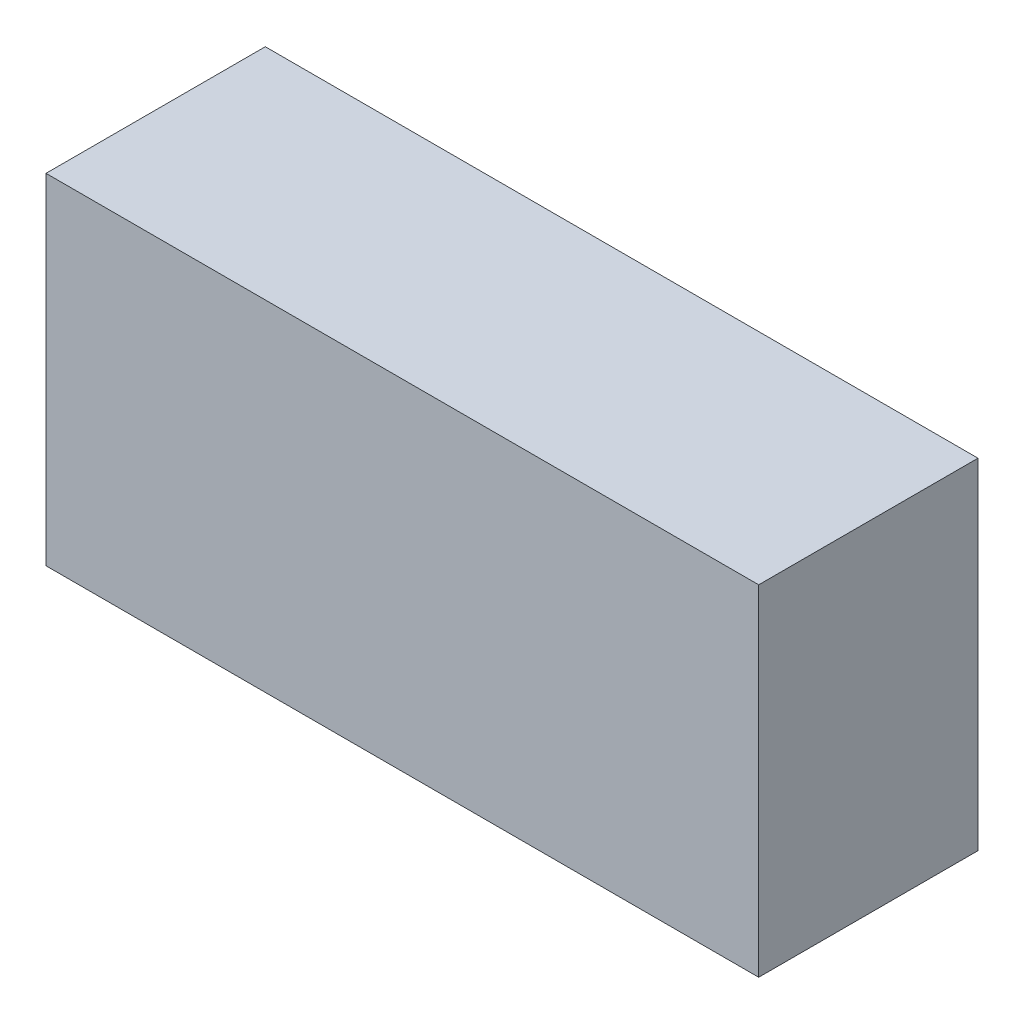
from build123d import *

# Parameters (mm, degrees)
SKETCH_1_W      = 19.5
SKETCH_1_H      = 6
EXTRUDE_1_DEPTH = 9.3
SKETCH_2_W      = 0.6
SKETCH_2_H      = 0.3
EXTRUDE_2_DEPTH = 3
EXTRUDE_3_DEPTH = 0.2


with BuildPart() as part:
    # Эскиз1 → Бобышка-Вытянуть1 (new body)
    with BuildSketch(Plane(origin=(0, 0, 0), x_dir=(1, 0, 0), z_dir=(0, 1, 0))):
        Rectangle(SKETCH_1_W, SKETCH_1_H)
    extrude(amount=EXTRUDE_1_DEPTH)

    # Эскиз2 → Бобышка-Вытянуть2 (add)
    with BuildSketch(Plane.XZ):
        with Locations((-7.62, -1.35)):
            Rectangle(SKETCH_2_W, SKETCH_2_H)
        with Locations((-5.08, -1.35)):
            Rectangle(SKETCH_2_W, SKETCH_2_H)
        with Locations((0, -1.35)):
            Rectangle(SKETCH_2_W, SKETCH_2_H)
        with Locations((5.08, -1.35)):
            Rectangle(SKETCH_2_W, SKETCH_2_H)
    extrude(amount=EXTRUDE_2_DEPTH)

    # Эскиз3 → Бобышка-Вытянуть3 (add)
    with BuildSketch(Plane(origin=(0, 9.3, 0), x_dir=(1, 0, 0), z_dir=(0, 1, 0))):
        with BuildLine():
            Line((-5.993653669, -1.1506083), (-5.993653669, 1.495225034))
            Line((-5.993653669, 1.495225034), (-5.726526265, 1.495225034))
            add(Edge.make_bspline(
                [(-5.726526265, 1.495225034), (-5.703199399, 1.494894605), (-5.65827213, 1.494258204), (-5.593328368, 1.490121291), (-5.533294043, 1.482863062), (-5.478257825, 1.472268509), (-5.427978548, 1.459234752), (-5.382722262, 1.442777118), (-5.342163377, 1.423550544), (-5.318249105, 1.407525081), (-5.30675463, 1.39982239)],
                knots=[0, 0, 0, 0, 6.998e-05, 0.000134781, 0.00019513, 0.000251262, 0.000302815, 0.000350769, 0.00039557, 0.000437033, 0.000437033, 0.000437033, 0.000437033], degree=3))
            add(Edge.make_bspline(
                [(-5.30675463, 1.39982239), (-5.291259723, 1.387980041), (-5.259666671, 1.363834307), (-5.216878942, 1.320049614), (-5.176018095, 1.270953839), (-5.138198125, 1.215037198), (-5.103093917, 1.153229673), (-5.069860634, 1.085379539), (-5.040008142, 1.011214307), (-5.012613306, 0.931196499), (-4.987736933, 0.846373762), (-4.966676113, 0.756972928), (-4.948733764, 0.663775398), (-4.933891633, 0.566532567), (-4.922334069, 0.465223791), (-4.913792213, 0.359881256), (-4.909099881, 0.250617555), (-4.908492313, 0.176552723), (-4.908183583, 0.138917442)],
                knots=[0, 0, 0, 0, 5.8439e-05, 0.000119153, 0.000183146, 0.000249888, 0.000321348, 0.000396253, 0.000476369, 0.000561014, 0.000649908, 0.00074144, 0.000836447, 0.000934568, 0.00103647, 0.001142284, 0.001251571, 0.001364475, 0.001364475, 0.001364475, 0.001364475], degree=3))
            add(Edge.make_bspline(
                [(-4.908183583, 0.138917442), (-4.908280711, 0.106227192), (-4.908471905, 0.041877192), (-4.913150802, -0.053011126), (-4.919308515, -0.144931602), (-4.928055359, -0.233911091), (-4.940620124, -0.319900369), (-4.954621979, -0.403063397), (-4.971578805, -0.483169429), (-4.991199381, -0.559859585), (-5.012673437, -0.632560972), (-5.036144523, -0.700772196), (-5.060756945, -0.763964681), (-5.08687661, -0.822459494), (-5.11469083, -0.875845291), (-5.14459931, -0.924137506), (-5.175194817, -0.968146848), (-5.208238178, -1.00695942), (-5.243405122, -1.041684613), (-5.282312993, -1.070675465), (-5.324207669, -1.095483025), (-5.369598006, -1.115586755), (-5.418401512, -1.131573487), (-5.470683253, -1.142394162), (-5.525977989, -1.149628644), (-5.56396405, -1.150276458), (-5.583422299, -1.1506083)],
                knots=[0, 0, 0, 0, 9.8058e-05, 0.000193026, 0.000284939, 0.000374436, 0.000461159, 0.000545593, 0.000627403, 0.000706717, 0.000783019, 0.000854758, 0.000923064, 0.000986404, 0.001046858, 0.001103491, 0.001156725, 0.001207487, 0.001256214, 0.001304658, 0.001352653, 0.001402001, 0.001453289, 0.00150641, 0.00156196, 0.0016203, 0.0016203, 0.0016203, 0.0016203], degree=3))
            Line((-5.583422299, -1.1506083), (-5.993653669, -1.1506083))
        make_face()
        with BuildLine():
            Line((-5.857969908, -0.879240778), (-5.712215868, -0.879240778))
            add(Edge.make_bspline(
                [(-5.712215868, -0.879240778), (-5.691187559, -0.879056917), (-5.650871591, -0.878704415), (-5.592868926, -0.875504605), (-5.539970165, -0.870356677), (-5.491975474, -0.863079212), (-5.449019914, -0.853425769), (-5.410665043, -0.842750873), (-5.377422356, -0.829210676), (-5.358215906, -0.817468128), (-5.349155806, -0.811928913)],
                knots=[0, 0, 0, 0, 6.3081e-05, 0.00012094, 0.000174206, 0.000222481, 0.000266459, 0.00030621, 0.000341843, 0.000373662, 0.000373662, 0.000373662, 0.000373662], degree=3))
            add(Edge.make_bspline(
                [(-5.349155806, -0.811928913), (-5.337504042, -0.803307558), (-5.313789347, -0.785760618), (-5.280583663, -0.754767955), (-5.250258232, -0.718316423), (-5.220506136, -0.67810954), (-5.194552767, -0.631854361), (-5.168983681, -0.581836894), (-5.145554456, -0.526783834), (-5.124665533, -0.467032902), (-5.105604787, -0.403212154), (-5.089398291, -0.335730556), (-5.074936985, -0.265071796), (-5.063189934, -0.190820741), (-5.055092671, -0.112940991), (-5.048787041, -0.03182255), (-5.044151944, 0.052648833), (-5.043963526, 0.110113423), (-5.043867344, 0.139447456)],
                knots=[0, 0, 0, 0, 4.3464e-05, 8.8463e-05, 0.000135833, 0.000185556, 0.000238281, 0.000294694, 0.000354058, 0.000417592, 0.000484502, 0.00055379, 0.00062572, 0.000700832, 0.000779205, 0.000860546, 0.000944925, 0.001032914, 0.001032914, 0.001032914, 0.001032914], degree=3))
            add(Edge.make_bspline(
                [(-5.043867344, 0.139447456), (-5.044257686, 0.170367783), (-5.045023027, 0.230993015), (-5.04851762, 0.320105791), (-5.055303295, 0.405703496), (-5.065721936, 0.487818585), (-5.0773982, 0.566813362), (-5.093024206, 0.642256147), (-5.110894459, 0.714268364), (-5.131375406, 0.782633857), (-5.154756204, 0.846351158), (-5.179273421, 0.905648959), (-5.207154577, 0.959280213), (-5.236388534, 1.0081843), (-5.26864597, 1.051395115), (-5.302252635, 1.09000415), (-5.339137971, 1.122477508), (-5.365409332, 1.140706418), (-5.378306614, 1.149655456)],
                knots=[0, 0, 0, 0, 9.2766e-05, 0.000181886, 0.000267496, 0.000350263, 0.000430171, 0.000506986, 0.000581287, 0.000652715, 0.000720955, 0.000784843, 0.000845053, 0.000902138, 0.000955564, 0.001006622, 0.001055435, 0.001102508, 0.001102508, 0.001102508, 0.001102508], degree=3))
            add(Edge.make_bspline(
                [(-5.378306614, 1.149655456), (-5.388955984, 1.155743208), (-5.411039459, 1.168367307), (-5.448391882, 1.183007997), (-5.490098558, 1.195464632), (-5.536608314, 1.206268717), (-5.588034553, 1.213841748), (-5.644095768, 1.219565094), (-5.704918011, 1.223470072), (-5.747013657, 1.223724871), (-5.76892744, 1.223857512)],
                knots=[0, 0, 0, 0, 3.6759e-05, 7.6226e-05, 0.000119987, 0.000167301, 0.000219323, 0.000275807, 0.000336342, 0.000402072, 0.000402072, 0.000402072, 0.000402072], degree=3))
            Line((-5.76892744, 1.223857512), (-5.857969908, 1.223857512))
            Line((-5.857969908, 1.223857512), (-5.857969908, -0.879240778))
        make_face(mode=Mode.SUBTRACT)
        with BuildLine():
            Line((-3.415662216, 1.009731578), (-3.519545095, 0.850727171))
            add(Edge.make_bspline(
                [(-3.519545095, 0.850727171), (-3.534179354, 0.884905992), (-3.562170932, 0.950281296), (-3.611133312, 1.040000729), (-3.665533305, 1.116106536), (-3.72384652, 1.179351808), (-3.785927203, 1.2295169), (-3.851769423, 1.265264449), (-3.920886372, 1.287938638), (-3.968476618, 1.290444177), (-3.992318199, 1.291699393)],
                knots=[0, 0, 0, 0, 0.000111505, 0.00021328, 0.000305946, 0.000391448, 0.000470663, 0.000544181, 0.000615258, 0.000686614, 0.000686614, 0.000686614, 0.000686614], degree=3))
            add(Edge.make_bspline(
                [(-3.992318199, 1.291699393), (-4.005431836, 1.291384283), (-4.03169845, 1.290753119), (-4.070396571, 1.282732829), (-4.108512905, 1.271147784), (-4.145817601, 1.254474313), (-4.182279862, 1.233158987), (-4.218304257, 1.207461497), (-4.252957775, 1.176608367), (-4.299075833, 1.128977162), (-4.352642098, 1.059690199), (-4.408114943, 0.964195578), (-4.457114694, 0.856544197), (-4.497127403, 0.73650285), (-4.529213424, 0.606387938), (-4.552370998, 0.467849217), (-4.566279092, 0.321350851), (-4.568060213, 0.221100812), (-4.568974182, 0.169658294)],
                knots=[0, 0, 0, 0, 3.9278e-05, 7.8675e-05, 0.000118071, 0.000158647, 0.000200919, 0.000244603, 0.000291171, 0.000339898, 0.000443375, 0.000552908, 0.000670553, 0.000797599, 0.000931932, 0.001072217, 0.001218621, 0.001372929, 0.001372929, 0.001372929, 0.001372929], degree=3))
            add(Edge.make_bspline(
                [(-4.568974182, 0.169658294), (-4.568505048, 0.130597956), (-4.567586992, 0.054160166), (-4.559240598, -0.057952809), (-4.546936059, -0.165048085), (-4.528789063, -0.267326934), (-4.505707102, -0.364750482), (-4.477047103, -0.45737923), (-4.443102256, -0.544809514), (-4.404897438, -0.626691155), (-4.362284373, -0.700931952), (-4.317155352, -0.766581502), (-4.268464955, -0.821815298), (-4.217519197, -0.867484278), (-4.163381985, -0.903364651), (-4.106076555, -0.928124148), (-4.046251249, -0.944766536), (-4.0051504, -0.946304829), (-3.984367978, -0.947082659)],
                knots=[0, 0, 0, 0, 0.000117163, 0.000229279, 0.000337095, 0.000440441, 0.000540713, 0.000637275, 0.000731075, 0.000821883, 0.000908068, 0.000987615, 0.00106046, 0.00112842, 0.001192368, 0.001254309, 0.001315115, 0.00137731, 0.00137731, 0.00137731, 0.00137731], degree=3))
            add(Edge.make_bspline(
                [(-3.984367978, -0.947082659), (-3.961591638, -0.945772388), (-3.91597232, -0.943148013), (-3.849479838, -0.921072886), (-3.786097826, -0.886024876), (-3.72623861, -0.836482885), (-3.669438198, -0.773568722), (-3.615488809, -0.697122197), (-3.564594685, -0.606919476), (-3.53506219, -0.540833581), (-3.519545095, -0.506110436)],
                knots=[0, 0, 0, 0, 6.8191e-05, 0.000136581, 0.000207984, 0.00028447, 0.000368503, 0.0004616, 0.000564616, 0.000678669, 0.000678669, 0.000678669, 0.000678669], degree=3))
            Line((-3.519545095, -0.506110436), (-3.415662216, -0.663524799))
            add(Edge.make_bspline(
                [(-3.415662216, -0.663524799), (-3.423957596, -0.684978718), (-3.440269776, -0.727166079), (-3.467335967, -0.787728881), (-3.495194986, -0.84501035), (-3.525867748, -0.89780762), (-3.556548419, -0.947988701), (-3.590310996, -0.993379854), (-3.624691432, -1.035567179), (-3.660650472, -1.073847065), (-3.698141543, -1.107588466), (-3.736619231, -1.137280461), (-3.77637805, -1.161955477), (-3.816885086, -1.183164813), (-3.85890478, -1.199070077), (-3.902132842, -1.210062204), (-3.946310126, -1.217400972), (-3.976211705, -1.218098955), (-3.991258169, -1.21845018)],
                knots=[0, 0, 0, 0, 6.8994e-05, 0.00013567, 0.000198958, 0.000259965, 0.000318787, 0.00037529, 0.000429512, 0.000482002, 0.000532665, 0.000580686, 0.000627598, 0.000672873, 0.000717662, 0.000762012, 0.00080654, 0.000851641, 0.000851641, 0.000851641, 0.000851641], degree=3))
            add(Edge.make_bspline(
                [(-3.991258169, -1.21845018), (-4.019498028, -1.217044905), (-4.0752501, -1.214270565), (-4.156243448, -1.191380627), (-4.232478086, -1.154894405), (-4.303933806, -1.103497233), (-4.369809131, -1.03705277), (-4.431329731, -0.956814193), (-4.488334905, -0.862118671), (-4.520381829, -0.792319622), (-4.5371733, -0.755747355)],
                knots=[0, 0, 0, 0, 8.4598e-05, 0.000167017, 0.000250464, 0.000337091, 0.000429662, 0.000530164, 0.000639786, 0.000760445, 0.000760445, 0.000760445, 0.000760445], degree=3))
            add(Edge.make_bspline(
                [(-4.5371733, -0.755747355), (-4.550705935, -0.722524172), (-4.578175766, -0.655084593), (-4.611354565, -0.549272101), (-4.641067127, -0.438918067), (-4.663731428, -0.323171427), (-4.682780542, -0.202666631), (-4.694840811, -0.076988272), (-4.7032721, 0.053646598), (-4.704190154, 0.142436449), (-4.704657942, 0.187678793)],
                knots=[0, 0, 0, 0, 0.000107577, 0.000218371, 0.000332403, 0.000450276, 0.000572011, 0.000698267, 0.000828893, 0.000964602, 0.000964602, 0.000964602, 0.000964602], degree=3))
            add(Edge.make_bspline(
                [(-4.704657942, 0.187678793), (-4.704071921, 0.235219874), (-4.702922615, 0.328457448), (-4.693182896, 0.465378871), (-4.677450347, 0.596485968), (-4.655352591, 0.721825733), (-4.626464582, 0.841351733), (-4.592607123, 0.955511927), (-4.550817993, 1.063548764), (-4.503763829, 1.164964211), (-4.452114913, 1.257588782), (-4.39660512, 1.338869898), (-4.33732567, 1.407454084), (-4.27538001, 1.464439326), (-4.209548403, 1.508797556), (-4.140164332, 1.539888447), (-4.067577761, 1.559396918), (-4.017878723, 1.561837656), (-3.992848213, 1.563066914)],
                knots=[0, 0, 0, 0, 0.000142609, 0.000279686, 0.000411561, 0.00053861, 0.00066125, 0.000780297, 0.000895559, 0.001008427, 0.001115455, 0.00121337, 0.001303168, 0.001386845, 0.001465196, 0.00154016, 0.001614078, 0.00168908, 0.00168908, 0.00168908, 0.00168908], degree=3))
            add(Edge.make_bspline(
                [(-3.992848213, 1.563066914), (-3.977627939, 1.562703678), (-3.947380615, 1.561981816), (-3.902594067, 1.554813267), (-3.859097397, 1.543179618), (-3.816832763, 1.526858437), (-3.775181493, 1.507110913), (-3.73550092, 1.4809088), (-3.696205136, 1.451551931), (-3.658548924, 1.417201519), (-3.62206409, 1.379288724), (-3.587540342, 1.337134575), (-3.554988139, 1.291302038), (-3.522540397, 1.242799461), (-3.494096057, 1.189331801), (-3.46554633, 1.133068857), (-3.43918824, 1.072902791), (-3.423587095, 1.031011171), (-3.415662216, 1.009731578)],
                knots=[0, 0, 0, 0, 4.5631e-05, 9.0682e-05, 0.00013568, 0.000180469, 0.000226455, 0.00027365, 0.000322836, 0.000373499, 0.000426354, 0.000480576, 0.000536768, 0.000594983, 0.000655472, 0.000718285, 0.000784263, 0.000852377, 0.000852377, 0.000852377, 0.000852377], degree=3))
        make_face()
        with BuildLine():
            Line((-1.448247686, 1.009731578), (-1.552130565, 0.850727171))
            add(Edge.make_bspline(
                [(-1.552130565, 0.850727171), (-1.566764824, 0.884905992), (-1.594756402, 0.950281296), (-1.643718782, 1.040000729), (-1.698118775, 1.116106536), (-1.75643199, 1.179351808), (-1.818512673, 1.2295169), (-1.884354893, 1.265264449), (-1.953471842, 1.287938638), (-2.001062088, 1.290444177), (-2.024903669, 1.291699393)],
                knots=[0, 0, 0, 0, 0.000111505, 0.00021328, 0.000305946, 0.000391448, 0.000470663, 0.000544181, 0.000615258, 0.000686614, 0.000686614, 0.000686614, 0.000686614], degree=3))
            add(Edge.make_bspline(
                [(-2.024903669, 1.291699393), (-2.038017306, 1.291384283), (-2.06428392, 1.290753119), (-2.102982041, 1.282732829), (-2.141098375, 1.271147784), (-2.178403071, 1.254474313), (-2.214865332, 1.233158987), (-2.250889728, 1.207461497), (-2.285543246, 1.176608367), (-2.331661303, 1.128977162), (-2.385227568, 1.059690199), (-2.440700413, 0.964195578), (-2.489700164, 0.856544197), (-2.529712873, 0.73650285), (-2.561798894, 0.606387938), (-2.584956468, 0.467849217), (-2.598864562, 0.321350851), (-2.600645683, 0.221100812), (-2.601559652, 0.169658294)],
                knots=[0, 0, 0, 0, 3.9278e-05, 7.8675e-05, 0.000118071, 0.000158647, 0.000200919, 0.000244603, 0.000291171, 0.000339898, 0.000443375, 0.000552908, 0.000670553, 0.000797599, 0.000931932, 0.001072217, 0.001218621, 0.001372929, 0.001372929, 0.001372929, 0.001372929], degree=3))
            add(Edge.make_bspline(
                [(-2.601559652, 0.169658294), (-2.601090518, 0.130597956), (-2.600172462, 0.054160166), (-2.591826069, -0.057952809), (-2.579521529, -0.165048085), (-2.561374533, -0.267326934), (-2.538292572, -0.364750482), (-2.509632573, -0.45737923), (-2.475687726, -0.544809514), (-2.437482908, -0.626691155), (-2.394869843, -0.700931952), (-2.349740822, -0.766581502), (-2.301050425, -0.821815298), (-2.250104667, -0.867484278), (-2.195967455, -0.903364651), (-2.138662025, -0.928124148), (-2.078836719, -0.944766536), (-2.03773587, -0.946304829), (-2.016953448, -0.947082659)],
                knots=[0, 0, 0, 0, 0.000117163, 0.000229279, 0.000337095, 0.000440441, 0.000540713, 0.000637275, 0.000731075, 0.000821883, 0.000908068, 0.000987615, 0.00106046, 0.00112842, 0.001192368, 0.001254309, 0.001315115, 0.00137731, 0.00137731, 0.00137731, 0.00137731], degree=3))
            add(Edge.make_bspline(
                [(-2.016953448, -0.947082659), (-1.994177108, -0.945772388), (-1.94855779, -0.943148013), (-1.882065308, -0.921072886), (-1.818683296, -0.886024876), (-1.75882408, -0.836482885), (-1.702023668, -0.773568722), (-1.648074279, -0.697122197), (-1.597180155, -0.606919476), (-1.56764766, -0.540833581), (-1.552130565, -0.506110436)],
                knots=[0, 0, 0, 0, 6.8191e-05, 0.000136581, 0.000207984, 0.00028447, 0.000368503, 0.0004616, 0.000564616, 0.000678669, 0.000678669, 0.000678669, 0.000678669], degree=3))
            Line((-1.552130565, -0.506110436), (-1.448247686, -0.663524799))
            add(Edge.make_bspline(
                [(-1.448247686, -0.663524799), (-1.456543066, -0.684978718), (-1.472855246, -0.727166079), (-1.499921437, -0.787728881), (-1.527780456, -0.84501035), (-1.558453218, -0.89780762), (-1.589133889, -0.947988701), (-1.622896466, -0.993379854), (-1.657276903, -1.035567179), (-1.693235942, -1.073847065), (-1.730727013, -1.107588466), (-1.769204701, -1.137280461), (-1.80896352, -1.161955477), (-1.849470556, -1.183164813), (-1.89149025, -1.199070077), (-1.934718312, -1.210062204), (-1.978895596, -1.217400972), (-2.008797175, -1.218098955), (-2.023843639, -1.21845018)],
                knots=[0, 0, 0, 0, 6.8994e-05, 0.00013567, 0.000198958, 0.000259965, 0.000318787, 0.00037529, 0.000429512, 0.000482002, 0.000532665, 0.000580686, 0.000627598, 0.000672873, 0.000717662, 0.000762012, 0.00080654, 0.000851641, 0.000851641, 0.000851641, 0.000851641], degree=3))
            add(Edge.make_bspline(
                [(-2.023843639, -1.21845018), (-2.052083499, -1.217044905), (-2.10783557, -1.214270565), (-2.188828918, -1.191380627), (-2.265063556, -1.154894405), (-2.336519276, -1.103497233), (-2.402394601, -1.03705277), (-2.463915201, -0.956814193), (-2.520920375, -0.862118671), (-2.552967299, -0.792319622), (-2.56975877, -0.755747355)],
                knots=[0, 0, 0, 0, 8.4598e-05, 0.000167017, 0.000250464, 0.000337091, 0.000429662, 0.000530164, 0.000639786, 0.000760445, 0.000760445, 0.000760445, 0.000760445], degree=3))
            add(Edge.make_bspline(
                [(-2.56975877, -0.755747355), (-2.583291406, -0.722524172), (-2.610761236, -0.655084593), (-2.643940035, -0.549272101), (-2.673652597, -0.438918067), (-2.696316898, -0.323171427), (-2.715366012, -0.202666631), (-2.727426281, -0.076988272), (-2.73585757, 0.053646598), (-2.736775624, 0.142436449), (-2.737243412, 0.187678793)],
                knots=[0, 0, 0, 0, 0.000107577, 0.000218371, 0.000332403, 0.000450276, 0.000572011, 0.000698267, 0.000828893, 0.000964602, 0.000964602, 0.000964602, 0.000964602], degree=3))
            add(Edge.make_bspline(
                [(-2.737243412, 0.187678793), (-2.736657391, 0.235219874), (-2.735508085, 0.328457448), (-2.725768366, 0.465378871), (-2.710035817, 0.596485968), (-2.687938062, 0.721825733), (-2.659050052, 0.841351733), (-2.625192593, 0.955511927), (-2.583403463, 1.063548764), (-2.536349299, 1.164964211), (-2.484700383, 1.257588782), (-2.42919059, 1.338869898), (-2.36991114, 1.407454084), (-2.307965481, 1.464439326), (-2.242133873, 1.508797556), (-2.172749802, 1.539888447), (-2.100163231, 1.559396918), (-2.050464193, 1.561837656), (-2.025433684, 1.563066914)],
                knots=[0, 0, 0, 0, 0.000142609, 0.000279686, 0.000411561, 0.00053861, 0.00066125, 0.000780297, 0.000895559, 0.001008427, 0.001115455, 0.00121337, 0.001303168, 0.001386845, 0.001465196, 0.00154016, 0.001614078, 0.00168908, 0.00168908, 0.00168908, 0.00168908], degree=3))
            add(Edge.make_bspline(
                [(-2.025433684, 1.563066914), (-2.010213409, 1.562703678), (-1.979966085, 1.561981816), (-1.935179537, 1.554813267), (-1.891682868, 1.543179618), (-1.849418233, 1.526858437), (-1.807766963, 1.507110913), (-1.76808639, 1.4809088), (-1.728790606, 1.451551931), (-1.691134394, 1.417201519), (-1.65464956, 1.379288724), (-1.620125812, 1.337134575), (-1.587573609, 1.291302038), (-1.555125867, 1.242799461), (-1.526681527, 1.189331801), (-1.4981318, 1.133068857), (-1.47177371, 1.072902791), (-1.456172565, 1.031011171), (-1.448247686, 1.009731578)],
                knots=[0, 0, 0, 0, 4.5631e-05, 9.0682e-05, 0.00013568, 0.000180469, 0.000226455, 0.00027365, 0.000322836, 0.000373499, 0.000426354, 0.000480576, 0.000536768, 0.000594983, 0.000655472, 0.000718285, 0.000784263, 0.000852377, 0.000852377, 0.000852377, 0.000852377], degree=3))
        make_face()
        with BuildLine():
            add(Edge.make_bspline(
                [(-0.786259338, 0.81680623), (-0.768295824, 0.81600169), (-0.732566431, 0.81440146), (-0.680834558, 0.797931704), (-0.631820933, 0.772336496), (-0.584557205, 0.737517515), (-0.540776603, 0.69167794), (-0.499317995, 0.636359406), (-0.460000564, 0.571323038), (-0.437251962, 0.523403355), (-0.425319334, 0.498267402)],
                knots=[0, 0, 0, 0, 5.3744e-05, 0.000106896, 0.00016118, 0.000219166, 0.000282133, 0.000350611, 0.000426238, 0.000509673, 0.000509673, 0.000509673, 0.000509673], degree=3))
            add(Edge.make_bspline(
                [(-0.425319334, 0.498267402), (-0.414728297, 0.473668234), (-0.393285396, 0.423864093), (-0.367227345, 0.345950642), (-0.344949151, 0.264885756), (-0.326032015, 0.180605301), (-0.313037159, 0.092656107), (-0.301778331, 0.001715256), (-0.296325548, -0.092631811), (-0.295403832, -0.15664916), (-0.29493572, -0.189161652)],
                knots=[0, 0, 0, 0, 8.0318e-05, 0.000162614, 0.000246195, 0.000332485, 0.00042154, 0.00051279, 0.000607313, 0.000704858, 0.000704858, 0.000704858, 0.000704858], degree=3))
            add(Edge.make_bspline(
                [(-0.29493572, -0.189161652), (-0.295349578, -0.221853946), (-0.296164678, -0.286241839), (-0.302406615, -0.381280091), (-0.313947295, -0.473153634), (-0.328136117, -0.562148356), (-0.348363023, -0.647748537), (-0.37105115, -0.730502442), (-0.399616521, -0.809793204), (-0.431334519, -0.885135131), (-0.466002773, -0.954682557), (-0.504376532, -1.015419427), (-0.54439823, -1.067563046), (-0.587749138, -1.110045823), (-0.633497994, -1.143475031), (-0.68201447, -1.167387439), (-0.73332845, -1.181735338), (-0.768503084, -1.183591994), (-0.786259338, -1.18452924)],
                knots=[0, 0, 0, 0, 9.8076e-05, 0.000193161, 0.000285527, 0.000375798, 0.000463354, 0.000549262, 0.000633082, 0.000715969, 0.000794428, 0.000865891, 0.000931204, 0.000991173, 0.001047364, 0.001100461, 0.001152664, 0.00120588, 0.00120588, 0.00120588, 0.00120588], degree=3))
            add(Edge.make_bspline(
                [(-0.786259338, -1.18452924), (-0.804011064, -1.183573351), (-0.839347322, -1.181670576), (-0.890886446, -1.167497137), (-0.939563391, -1.143481638), (-0.985339642, -1.109901724), (-1.029169741, -1.067601137), (-1.069769751, -1.015582232), (-1.108089348, -0.954665248), (-1.142724365, -0.885122221), (-1.174700554, -0.80992249), (-1.202146645, -0.73027545), (-1.226196077, -0.647953081), (-1.244970492, -0.561981879), (-1.260604899, -0.473275738), (-1.270903559, -0.381222106), (-1.277484843, -0.286251606), (-1.278252974, -0.221857236), (-1.278642985, -0.189161652)],
                knots=[0, 0, 0, 0, 5.3216e-05, 0.00010593, 0.000159027, 0.000215219, 0.000275568, 0.000341209, 0.000412672, 0.000491131, 0.000574018, 0.000657661, 0.000743715, 0.000831155, 0.000921514, 0.001013817, 0.001108903, 0.001206978, 0.001206978, 0.001206978, 0.001206978], degree=3))
            add(Edge.make_bspline(
                [(-1.278642985, -0.189161652), (-1.278178442, -0.156824813), (-1.277261294, -0.092982179), (-1.271726731, 0.001172955), (-1.260822889, 0.092024459), (-1.246682351, 0.179421159), (-1.228663621, 0.263684197), (-1.206507249, 0.344591254), (-1.180178476, 0.422410198), (-1.158834277, 0.472072399), (-1.148259371, 0.496677358)],
                knots=[0, 0, 0, 0, 9.7016e-05, 0.000191538, 0.000282789, 0.000371404, 0.000457064, 0.000541156, 0.00062295, 0.000703268, 0.000703268, 0.000703268, 0.000703268], degree=3))
            add(Edge.make_bspline(
                [(-1.148259371, 0.496677358), (-1.136349283, 0.522002036), (-1.113704774, 0.570151549), (-1.074129905, 0.635502295), (-1.032470577, 0.691022688), (-0.988335287, 0.736710879), (-0.941784971, 0.772713123), (-0.892146266, 0.797870409), (-0.840124761, 0.814365676), (-0.804223805, 0.81599229), (-0.786259338, 0.81680623)],
                knots=[0, 0, 0, 0, 8.391e-05, 0.000159537, 0.000228758, 0.000291725, 0.000349604, 0.000404359, 0.000458019, 0.000511763, 0.000511763, 0.000511763, 0.000511763], degree=3))
        make_face()
        with BuildLine():
            add(Edge.make_bspline(
                [(-0.786789353, 0.579359649), (-0.798886218, 0.578626652), (-0.82301766, 0.577164431), (-0.858223157, 0.565790098), (-0.891985195, 0.54813109), (-0.924214219, 0.522841727), (-0.955425443, 0.491122233), (-0.984444916, 0.45166165), (-1.012618435, 0.40574868), (-1.03916386, 0.353446946), (-1.063119203, 0.295895135), (-1.08500333, 0.23517698), (-1.103007324, 0.171409901), (-1.117135786, 0.10458493), (-1.128804156, 0.034930636), (-1.137341087, -0.03775207), (-1.142056769, -0.113305513), (-1.142654463, -0.164597934), (-1.142959224, -0.190751696)],
                knots=[0, 0, 0, 0, 3.6231e-05, 7.2276e-05, 0.000109971, 0.000150042, 0.000194642, 0.000243086, 0.000296628, 0.000356124, 0.000418829, 0.000483539, 0.000549644, 0.000617424, 0.000688351, 0.000761457, 0.00083687, 0.000915328, 0.000915328, 0.000915328, 0.000915328], degree=3))
            add(Edge.make_bspline(
                [(-1.142959224, -0.190751696), (-1.142326427, -0.224516359), (-1.141078433, -0.291106612), (-1.131865071, -0.389182871), (-1.117149789, -0.483748531), (-1.096763284, -0.57357852), (-1.071413696, -0.656915723), (-1.040686032, -0.730903139), (-1.007123923, -0.795724965), (-0.968484024, -0.849369276), (-0.926864889, -0.892616434), (-0.88217378, -0.923391467), (-0.835469388, -0.943959249), (-0.80288704, -0.946049798), (-0.786789353, -0.947082659)],
                knots=[0, 0, 0, 0, 0.000101283, 0.000199749, 0.000295251, 0.000388211, 0.000475888, 0.000556206, 0.000628288, 0.000694338, 0.000753929, 0.000807295, 0.000856506, 0.000904562, 0.000904562, 0.000904562, 0.000904562], degree=3))
            add(Edge.make_bspline(
                [(-0.786789353, -0.947082659), (-0.77069017, -0.946051352), (-0.738104797, -0.943963948), (-0.691424169, -0.923371461), (-0.646733496, -0.892772774), (-0.605620341, -0.849183125), (-0.567073213, -0.795601378), (-0.532659256, -0.731179148), (-0.50286572, -0.656761062), (-0.477438741, -0.573529964), (-0.456264431, -0.483823389), (-0.441761172, -0.389172967), (-0.432487835, -0.291109204), (-0.431248093, -0.224517231), (-0.430619481, -0.190751696)],
                knots=[0, 0, 0, 0, 4.8056e-05, 9.7268e-05, 0.000150634, 0.000209853, 0.000275903, 0.000348236, 0.000428353, 0.00051603, 0.000609109, 0.000704611, 0.000803077, 0.00090436, 0.00090436, 0.00090436, 0.00090436], degree=3))
            add(Edge.make_bspline(
                [(-0.430619481, -0.190751696), (-0.430925486, -0.16459819), (-0.431525619, -0.11330627), (-0.43622373, -0.037749215), (-0.444824287, 0.034920411), (-0.456272696, 0.104658662), (-0.471208982, 0.171356384), (-0.489265037, 0.235049505), (-0.51018443, 0.296139923), (-0.535093194, 0.353316751), (-0.561497144, 0.405725377), (-0.589562433, 0.451883468), (-0.619282428, 0.490756408), (-0.649875101, 0.523027156), (-0.68215154, 0.548104718), (-0.715878749, 0.56579737), (-0.750923549, 0.577105458), (-0.774871983, 0.578610634), (-0.786789353, 0.579359649)],
                knots=[0, 0, 0, 0, 7.8458e-05, 0.000153871, 0.000226977, 0.000297904, 0.000365798, 0.000431903, 0.000496436, 0.00055935, 0.000618846, 0.000672388, 0.000721152, 0.000765382, 0.000805454, 0.000843148, 0.000879193, 0.000914897, 0.000914897, 0.000914897, 0.000914897], degree=3))
        make_face(mode=Mode.SUBTRACT)
        with BuildLine():
            Line((-0.057489139, 0.78288529), (0.078194622, 0.78288529))
            Line((0.078194622, 0.78288529), (0.078194622, 0.434135624))
            add(Edge.make_bspline(
                [(0.078194622, 0.434135624), (0.090473003, 0.465415577), (0.113637798, 0.524429355), (0.152949616, 0.604831872), (0.194834574, 0.671538016), (0.238889072, 0.724881992), (0.285305471, 0.765981762), (0.333906321, 0.795133405), (0.385061357, 0.813338806), (0.420090417, 0.815653081), (0.437544582, 0.81680623)],
                knots=[0, 0, 0, 0, 0.000100786, 0.000190147, 0.000268074, 0.000336546, 0.000397026, 0.00045311, 0.000505739, 0.000558007, 0.000558007, 0.000558007, 0.000558007], degree=3))
            add(Edge.make_bspline(
                [(0.437544582, 0.81680623), (0.455045862, 0.815427277), (0.490332639, 0.812646977), (0.541313346, 0.791060513), (0.58784322, 0.755227665), (0.630597175, 0.706886804), (0.668635136, 0.647182672), (0.702902382, 0.578089279), (0.729745898, 0.498723058), (0.748524014, 0.426327988), (0.761213854, 0.361580804), (0.768691001, 0.305613031), (0.775834597, 0.243267015), (0.780778935, 0.174469796), (0.78505622, 0.099200266), (0.788120457, 0.017386139), (0.790404417, -0.070778848), (0.790490142, -0.13174174), (0.790534365, -0.163190932)],
                knots=[0, 0, 0, 0, 5.2396e-05, 0.000105644, 0.000163203, 0.000227379, 0.000298237, 0.000375036, 0.000458179, 0.000549065, 0.000599271, 0.000656013, 0.000718406, 0.000787511, 0.000862893, 0.000944577, 0.001033115, 0.001127459, 0.001127459, 0.001127459, 0.001127459], degree=3))
            Line((0.790534365, -0.163190932), (0.790534365, -1.1506083))
            Line((0.790534365, -1.1506083), (0.654850605, -1.1506083))
            Line((0.654850605, -1.1506083), (0.654850605, -0.241103091))
            add(Edge.make_bspline(
                [(0.654850605, -0.241103091), (0.654901746, -0.214778869), (0.654999567, -0.164426518), (0.654336012, -0.092345224), (0.653763884, -0.02697789), (0.653483685, 0.031507299), (0.65219473, 0.083088841), (0.651385129, 0.127800377), (0.649722976, 0.165603399), (0.648504281, 0.188562951), (0.647960414, 0.198809102)],
                knots=[0, 0, 0, 0, 7.8972e-05, 0.000151056, 0.00021625, 0.000275084, 0.000326506, 0.00037104, 0.000409234, 0.000440016, 0.000440016, 0.000440016, 0.000440016], degree=3))
            add(Edge.make_bspline(
                [(0.647960414, 0.198809102), (0.64571324, 0.228557571), (0.641486532, 0.28451144), (0.62687992, 0.362254523), (0.606153204, 0.428513347), (0.578600593, 0.482865252), (0.545764184, 0.526038935), (0.507034395, 0.556869493), (0.463086331, 0.576376873), (0.43173428, 0.578355115), (0.415813979, 0.579359649)],
                knots=[0, 0, 0, 0, 8.9445e-05, 0.000168238, 0.00023679, 0.000297, 0.000350226, 0.000398154, 0.000444225, 0.000491756, 0.000491756, 0.000491756, 0.000491756], degree=3))
            add(Edge.make_bspline(
                [(0.415813979, 0.579359649), (0.406406609, 0.579000598), (0.387683893, 0.578286007), (0.360081539, 0.570938273), (0.33358275, 0.559116182), (0.307478381, 0.542965196), (0.283097594, 0.521327564), (0.258056496, 0.496442104), (0.235236892, 0.465799284), (0.204330303, 0.41932629), (0.17016809, 0.353300208), (0.137666461, 0.265797944), (0.111887842, 0.169787872), (0.101560782, 0.102299758), (0.096215121, 0.067365458)],
                knots=[0, 0, 0, 0, 2.8171e-05, 5.6066e-05, 8.5018e-05, 0.000115019, 0.00014773, 0.000182586, 0.000220751, 0.000262058, 0.000350012, 0.000442939, 0.000541675, 0.000647632, 0.000647632, 0.000647632, 0.000647632], degree=3))
            add(Edge.make_bspline(
                [(0.096215121, 0.067365458), (0.094722013, 0.054299406), (0.091458026, 0.02573656), (0.088018321, -0.020765347), (0.084618429, -0.074640369), (0.082974455, -0.135808744), (0.080627648, -0.204343685), (0.078962715, -0.280139749), (0.078777293, -0.363360428), (0.078394295, -0.421308327), (0.078194622, -0.451518923)],
                knots=[0, 0, 0, 0, 3.945e-05, 8.6238e-05, 0.000139864, 0.000201382, 0.000269787, 0.000345596, 0.00042881, 0.000519444, 0.000519444, 0.000519444, 0.000519444], degree=3))
            Line((0.078194622, -0.451518923), (0.078194622, -1.1506083))
            Line((0.078194622, -1.1506083), (-0.057489139, -1.1506083))
            Line((-0.057489139, -1.1506083), (-0.057489139, 0.78288529))
        make_face()
        Polygon((0.960139066, 0.78288529), (1.109073194, 0.78288529), (1.418071759, -0.572362273), (1.727070323, 0.78288529), (1.876004451, 0.78288529), (1.435032229, -1.1506083), (1.401111288, -1.1506083), align=None)
        with BuildLine():
            Line((2.889922553, -0.540031376), (2.995395476, -0.650804447))
            add(Edge.make_bspline(
                [(2.995395476, -0.650804447), (2.986843686, -0.680395232), (2.970487553, -0.736990493), (2.942521837, -0.817003839), (2.912057191, -0.887868362), (2.879457332, -0.949958174), (2.845538594, -1.004400122), (2.808633959, -1.051024034), (2.770596064, -1.092025781), (2.729664271, -1.125657126), (2.686351339, -1.152060238), (2.640309908, -1.171116269), (2.591364043, -1.182420247), (2.557661232, -1.183821614), (2.540642872, -1.18452924)],
                knots=[0, 0, 0, 0, 9.2394e-05, 0.000176713, 0.000254103, 0.000323567, 0.000386941, 0.00044621, 0.000501698, 0.000554428, 0.000604603, 0.000653324, 0.00070334, 0.000754356, 0.000754356, 0.000754356, 0.000754356], degree=3))
            add(Edge.make_bspline(
                [(2.540642872, -1.18452924), (2.521647414, -1.183640859), (2.484157345, -1.181887521), (2.429827944, -1.167040394), (2.379028756, -1.142547769), (2.331434963, -1.108631038), (2.287208639, -1.064982098), (2.246363966, -1.011876656), (2.208773445, -0.949358119), (2.175199734, -0.878407616), (2.14487345, -0.80181485), (2.118547256, -0.721543549), (2.095394935, -0.638913847), (2.077792903, -0.553454635), (2.063477122, -0.465928955), (2.052550216, -0.375963316), (2.046997499, -0.283399275), (2.046075144, -0.220792035), (2.045609152, -0.189161652)],
                knots=[0, 0, 0, 0, 5.6912e-05, 0.000112323, 0.000167559, 0.000225353, 0.000286821, 0.000353295, 0.000425831, 0.000505245, 0.00058851, 0.000672815, 0.000758581, 0.000845796, 0.000934411, 0.001024609, 0.001117544, 0.001212441, 0.001212441, 0.001212441, 0.001212441], degree=3))
            add(Edge.make_bspline(
                [(2.045609152, -0.189161652), (2.045873668, -0.15947328), (2.04639684, -0.100754205), (2.051786754, -0.01391278), (2.060890014, 0.070583535), (2.073022901, 0.152637188), (2.088213979, 0.232307843), (2.107431802, 0.309412503), (2.130019131, 0.384099099), (2.148006457, 0.4324547), (2.156912237, 0.456396241)],
                knots=[0, 0, 0, 0, 8.9057e-05, 0.000176141, 0.000260893, 0.000343945, 0.000424919, 0.000504105, 0.000582235, 0.000658852, 0.000658852, 0.000658852, 0.000658852], degree=3))
            add(Edge.make_bspline(
                [(2.156912237, 0.456396241), (2.168632995, 0.484695311), (2.191034257, 0.538781819), (2.230346554, 0.612710631), (2.273772183, 0.674835599), (2.319012731, 0.726769821), (2.368669983, 0.766678288), (2.420853593, 0.796196308), (2.477065364, 0.813266793), (2.515446352, 0.815619232), (2.534812711, 0.81680623)],
                knots=[0, 0, 0, 0, 9.1865e-05, 0.000175578, 0.000250565, 0.000318877, 0.000381455, 0.00044076, 0.00049777, 0.000555835, 0.000555835, 0.000555835, 0.000555835], degree=3))
            add(Edge.make_bspline(
                [(2.534812711, 0.81680623), (2.554748952, 0.815766124), (2.594405397, 0.813697184), (2.65183856, 0.794307188), (2.706052042, 0.764148707), (2.757036124, 0.721954325), (2.803761609, 0.667157498), (2.84741589, 0.600847797), (2.889054115, 0.523315753), (2.911878401, 0.466198207), (2.923843493, 0.436255683)],
                knots=[0, 0, 0, 0, 5.9647e-05, 0.000118648, 0.000179857, 0.000245006, 0.000316006, 0.000395092, 0.000482825, 0.000579493, 0.000579493, 0.000579493, 0.000579493], degree=3))
            add(Edge.make_bspline(
                [(2.923843493, 0.436255683), (2.932239182, 0.413201379), (2.949323145, 0.366289341), (2.97040868, 0.292615183), (2.988276388, 0.214921509), (3.003065321, 0.133027608), (3.014880028, 0.047109802), (3.022341437, -0.043136194), (3.02798877, -0.137504611), (3.028867626, -0.201873), (3.029316417, -0.234742915)],
                knots=[0, 0, 0, 0, 7.3588e-05, 0.000149741, 0.00022971, 0.00031267, 0.000399321, 0.000489773, 0.000584265, 0.00068287, 0.00068287, 0.00068287, 0.00068287], degree=3))
            Line((3.029316417, -0.234742915), (2.181292912, -0.234742915))
            add(Edge.make_bspline(
                [(2.181292912, -0.234742915), (2.181678495, -0.260200358), (2.182434624, -0.310122463), (2.188977195, -0.383062876), (2.196139028, -0.452732985), (2.208276721, -0.518418832), (2.222091078, -0.580931888), (2.240558167, -0.639413961), (2.260293019, -0.695188709), (2.284027297, -0.746442985), (2.309787431, -0.793118227), (2.337226816, -0.833957866), (2.365822227, -0.868954932), (2.396201902, -0.897441422), (2.428280632, -0.919689367), (2.462240249, -0.935137296), (2.497484372, -0.945279826), (2.521671877, -0.946482143), (2.533752681, -0.947082659)],
                knots=[0, 0, 0, 0, 7.6352e-05, 0.000149726, 0.000219611, 0.000286359, 0.000350001, 0.000411531, 0.000470216, 0.000527372, 0.000580756, 0.000630002, 0.000674791, 0.000716043, 0.00075456, 0.000791319, 0.000827577, 0.000863758, 0.000863758, 0.000863758, 0.000863758], degree=3))
            add(Edge.make_bspline(
                [(2.533752681, -0.947082659), (2.545639735, -0.946606939), (2.569542184, -0.945650364), (2.604974005, -0.936674712), (2.639639986, -0.922120349), (2.67346179, -0.902275022), (2.70623002, -0.878366002), (2.735712001, -0.849147568), (2.763591626, -0.817379685), (2.789389289, -0.780548935), (2.813785808, -0.735605494), (2.838760192, -0.680839707), (2.864834398, -0.614459415), (2.881140963, -0.566083374), (2.889922553, -0.540031376)],
                knots=[0, 0, 0, 0, 3.561e-05, 7.1604e-05, 0.000108909, 0.000148091, 0.000189008, 0.00023024, 0.000272322, 0.0003157, 0.000364811, 0.00042552, 0.000496187, 0.000578655, 0.000578655, 0.000578655, 0.000578655], degree=3))
        make_face()
        with BuildLine():
            add(Edge.make_bspline(
                [(2.893632656, 0.002703666), (2.889284009, 0.034010969), (2.881026115, 0.093462193), (2.865510163, 0.177480153), (2.846565928, 0.2513368), (2.824740419, 0.316092891), (2.799611473, 0.373076112), (2.771085822, 0.423985739), (2.738043629, 0.468621467), (2.702141544, 0.507162291), (2.664626545, 0.539697143), (2.624200455, 0.561871031), (2.583241391, 0.577163797), (2.555082473, 0.57863361), (2.541172887, 0.579359649)],
                knots=[0, 0, 0, 0, 9.4819e-05, 0.000180058, 0.000256161, 0.000323372, 0.000384829, 0.000442746, 0.000498081, 0.000550958, 0.000600633, 0.000646192, 0.000688765, 0.000730323, 0.000730323, 0.000730323, 0.000730323], degree=3))
            add(Edge.make_bspline(
                [(2.541172887, 0.579359649), (2.529816757, 0.578884512), (2.507133469, 0.577935449), (2.47385806, 0.569147519), (2.442189002, 0.554200788), (2.410982235, 0.534723183), (2.382227004, 0.508241261), (2.354132644, 0.476873625), (2.327269582, 0.439956298), (2.31141713, 0.412390057), (2.303196291, 0.398094625)],
                knots=[0, 0, 0, 0, 3.4024e-05, 6.7962e-05, 0.000102352, 0.000138815, 0.000177856, 0.000219143, 0.000265047, 0.000314495, 0.000314495, 0.000314495, 0.000314495], degree=3))
            add(Edge.make_bspline(
                [(2.303196291, 0.398094625), (2.297196818, 0.386514034), (2.284674217, 0.362342057), (2.268605675, 0.323043588), (2.25313396, 0.279922048), (2.238820492, 0.232510016), (2.225838271, 0.18081587), (2.213491386, 0.125196651), (2.203104027, 0.065346625), (2.196768047, 0.02409169), (2.19348325, 0.002703666)],
                knots=[0, 0, 0, 0, 3.911e-05, 8.1633e-05, 0.000127233, 0.000176527, 0.000230132, 0.000287103, 0.000347404, 0.000412322, 0.000412322, 0.000412322, 0.000412322], degree=3))
            Line((2.19348325, 0.002703666), (2.893632656, 0.002703666))
        make_face(mode=Mode.SUBTRACT)
        with BuildLine():
            Line((3.232842058, 0.78288529), (3.368525818, 0.78288529))
            Line((3.368525818, 0.78288529), (3.368525818, 0.498267402))
            add(Edge.make_bspline(
                [(3.368525818, 0.498267402), (3.377158654, 0.524552332), (3.393329778, 0.573789553), (3.42143135, 0.640457161), (3.449280172, 0.695972089), (3.478235876, 0.740367655), (3.508981153, 0.773639524), (3.5391453, 0.798808716), (3.571522866, 0.813693408), (3.593653396, 0.815789862), (3.604382355, 0.81680623)],
                knots=[0, 0, 0, 0, 8.2969e-05, 0.000155418, 0.000216813, 0.000269145, 0.000313783, 0.000352274, 0.000386446, 0.000418603, 0.000418603, 0.000418603, 0.000418603], degree=3))
            add(Edge.make_bspline(
                [(3.604382355, 0.81680623), (3.612636765, 0.815852155), (3.63030099, 0.813810458), (3.656311976, 0.800158343), (3.682996722, 0.779137474), (3.699041042, 0.760599725), (3.70773522, 0.750554394)],
                knots=[0, 0, 0, 0, 2.4747e-05, 5.2957e-05, 8.6566e-05, 0.000126321, 0.000126321, 0.000126321, 0.000126321], degree=3))
            Line((3.70773522, 0.750554394), (3.642543413, 0.544908694))
            add(Edge.make_bspline(
                [(3.642543413, 0.544908694), (3.636790337, 0.549953037), (3.626169317, 0.559265631), (3.610540938, 0.570655945), (3.595769021, 0.577862983), (3.586068266, 0.578887071), (3.581591724, 0.579359649)],
                knots=[0, 0, 0, 0, 2.2938e-05, 4.2347e-05, 5.8007e-05, 7.1426e-05, 7.1426e-05, 7.1426e-05, 7.1426e-05], degree=3))
            add(Edge.make_bspline(
                [(3.581591724, 0.579359649), (3.571757888, 0.578001124), (3.550680791, 0.575089364), (3.522244285, 0.55270439), (3.494902966, 0.520205459), (3.467988632, 0.474936295), (3.443312282, 0.416541398), (3.422235918, 0.344225662), (3.403069108, 0.258414172), (3.39437154, 0.196066367), (3.389726406, 0.162768103)],
                knots=[0, 0, 0, 0, 2.9319e-05, 6.284e-05, 0.000104922, 0.000157007, 0.00021992, 0.000294699, 0.000382656, 0.000483477, 0.000483477, 0.000483477, 0.000483477], degree=3))
            add(Edge.make_bspline(
                [(3.389726406, 0.162768103), (3.388046347, 0.147406041), (3.38430524, 0.113198246), (3.380334433, 0.056444872), (3.376687708, -0.01087533), (3.37343455, -0.088612162), (3.371563998, -0.176789024), (3.369950645, -0.275372709), (3.368916238, -0.38455846), (3.368659912, -0.460882316), (3.368525818, -0.500810289)],
                knots=[0, 0, 0, 0, 4.6357e-05, 0.000103227, 0.000170641, 0.000248618, 0.000336626, 0.000435222, 0.00054441, 0.000664194, 0.000664194, 0.000664194, 0.000664194], degree=3))
            Line((3.368525818, -0.500810289), (3.368525818, -1.1506083))
            Line((3.368525818, -1.1506083), (3.232842058, -1.1506083))
            Line((3.232842058, -1.1506083), (3.232842058, 0.78288529))
        make_face()
        Polygon((3.911260861, 1.563066914), (4.046944622, 1.563066914), (4.046944622, 0.78288529), (4.216549323, 0.78288529), (4.216549323, 0.545438709), (4.046944622, 0.545438709), (4.046944622, -1.1506083), (3.911260861, -1.1506083), (3.911260861, 0.545438709), (3.74165616, 0.545438709), (3.74165616, 0.78288529), (3.911260861, 0.78288529), align=None)
        with BuildLine():
            Line((5.230467425, -0.540031376), (5.335940348, -0.650804447))
            add(Edge.make_bspline(
                [(5.335940348, -0.650804447), (5.327388558, -0.680395232), (5.311032425, -0.736990493), (5.283066708, -0.817003839), (5.252602063, -0.887868362), (5.220002204, -0.949958174), (5.186083466, -1.004400122), (5.149178831, -1.051024034), (5.111140936, -1.092025781), (5.070209142, -1.125657126), (5.026896211, -1.152060238), (4.98085478, -1.171116269), (4.931908915, -1.182420247), (4.898206104, -1.183821614), (4.881187744, -1.18452924)],
                knots=[0, 0, 0, 0, 9.2394e-05, 0.000176713, 0.000254103, 0.000323567, 0.000386941, 0.00044621, 0.000501698, 0.000554428, 0.000604603, 0.000653324, 0.00070334, 0.000754356, 0.000754356, 0.000754356, 0.000754356], degree=3))
            add(Edge.make_bspline(
                [(4.881187744, -1.18452924), (4.862192286, -1.183640859), (4.824702217, -1.181887521), (4.770372815, -1.167040394), (4.719573628, -1.142547769), (4.671979834, -1.108631038), (4.62775351, -1.064982098), (4.586908837, -1.011876656), (4.549318317, -0.949358119), (4.515744605, -0.878407616), (4.485418322, -0.80181485), (4.459092128, -0.721543549), (4.435939807, -0.638913847), (4.418337775, -0.553454635), (4.404021994, -0.465928955), (4.393095087, -0.375963316), (4.387542371, -0.283399275), (4.386620015, -0.220792035), (4.386154023, -0.189161652)],
                knots=[0, 0, 0, 0, 5.6912e-05, 0.000112323, 0.000167559, 0.000225353, 0.000286821, 0.000353295, 0.000425831, 0.000505245, 0.00058851, 0.000672815, 0.000758581, 0.000845796, 0.000934411, 0.001024609, 0.001117544, 0.001212441, 0.001212441, 0.001212441, 0.001212441], degree=3))
            add(Edge.make_bspline(
                [(4.386154023, -0.189161652), (4.38641854, -0.15947328), (4.386941712, -0.100754205), (4.392331626, -0.01391278), (4.401434885, 0.070583535), (4.413567773, 0.152637188), (4.428758851, 0.232307843), (4.447976673, 0.309412503), (4.470564003, 0.384099099), (4.488551329, 0.4324547), (4.497457108, 0.456396241)],
                knots=[0, 0, 0, 0, 8.9057e-05, 0.000176141, 0.000260893, 0.000343945, 0.000424919, 0.000504105, 0.000582235, 0.000658852, 0.000658852, 0.000658852, 0.000658852], degree=3))
            add(Edge.make_bspline(
                [(4.497457108, 0.456396241), (4.509177866, 0.484695311), (4.531579128, 0.538781819), (4.570891426, 0.612710631), (4.614317055, 0.674835599), (4.659557603, 0.726769821), (4.709214855, 0.766678288), (4.761398465, 0.796196308), (4.817610236, 0.813266793), (4.855991224, 0.815619232), (4.875357583, 0.81680623)],
                knots=[0, 0, 0, 0, 9.1865e-05, 0.000175578, 0.000250565, 0.000318877, 0.000381455, 0.00044076, 0.00049777, 0.000555835, 0.000555835, 0.000555835, 0.000555835], degree=3))
            add(Edge.make_bspline(
                [(4.875357583, 0.81680623), (4.895293824, 0.815766124), (4.934950269, 0.813697184), (4.992383432, 0.794307188), (5.046596914, 0.764148707), (5.097580996, 0.721954325), (5.144306481, 0.667157498), (5.187960762, 0.600847797), (5.229598987, 0.523315753), (5.252423273, 0.466198207), (5.264388365, 0.436255683)],
                knots=[0, 0, 0, 0, 5.9647e-05, 0.000118648, 0.000179857, 0.000245006, 0.000316006, 0.000395092, 0.000482825, 0.000579493, 0.000579493, 0.000579493, 0.000579493], degree=3))
            add(Edge.make_bspline(
                [(5.264388365, 0.436255683), (5.272784054, 0.413201379), (5.289868017, 0.366289341), (5.310953551, 0.292615183), (5.32882126, 0.214921509), (5.343610193, 0.133027608), (5.3554249, 0.047109802), (5.362886308, -0.043136194), (5.368533642, -0.137504611), (5.369412498, -0.201873), (5.369861288, -0.234742915)],
                knots=[0, 0, 0, 0, 7.3588e-05, 0.000149741, 0.00022971, 0.00031267, 0.000399321, 0.000489773, 0.000584265, 0.00068287, 0.00068287, 0.00068287, 0.00068287], degree=3))
            Line((5.369861288, -0.234742915), (4.521837784, -0.234742915))
            add(Edge.make_bspline(
                [(4.521837784, -0.234742915), (4.522223367, -0.260200358), (4.522979496, -0.310122463), (4.529522067, -0.383062876), (4.5366839, -0.452732985), (4.548821593, -0.518418832), (4.56263595, -0.580931888), (4.581103039, -0.639413961), (4.600837891, -0.695188709), (4.624572169, -0.746442985), (4.650332302, -0.793118227), (4.677771688, -0.833957866), (4.706367098, -0.868954932), (4.736746774, -0.897441422), (4.768825504, -0.919689367), (4.802785121, -0.935137296), (4.838029244, -0.945279826), (4.862216749, -0.946482143), (4.874297553, -0.947082659)],
                knots=[0, 0, 0, 0, 7.6352e-05, 0.000149726, 0.000219611, 0.000286359, 0.000350001, 0.000411531, 0.000470216, 0.000527372, 0.000580756, 0.000630002, 0.000674791, 0.000716043, 0.00075456, 0.000791319, 0.000827577, 0.000863758, 0.000863758, 0.000863758, 0.000863758], degree=3))
            add(Edge.make_bspline(
                [(4.874297553, -0.947082659), (4.886184606, -0.946606939), (4.910087056, -0.945650364), (4.945518877, -0.936674712), (4.980184858, -0.922120349), (5.014006662, -0.902275022), (5.046774892, -0.878366002), (5.076256872, -0.849147568), (5.104136498, -0.817379685), (5.129934161, -0.780548935), (5.154330679, -0.735605494), (5.179305064, -0.680839707), (5.20537927, -0.614459415), (5.221685835, -0.566083374), (5.230467425, -0.540031376)],
                knots=[0, 0, 0, 0, 3.561e-05, 7.1604e-05, 0.000108909, 0.000148091, 0.000189008, 0.00023024, 0.000272322, 0.0003157, 0.000364811, 0.00042552, 0.000496187, 0.000578655, 0.000578655, 0.000578655, 0.000578655], degree=3))
        make_face()
        with BuildLine():
            add(Edge.make_bspline(
                [(5.234177528, 0.002703666), (5.229828881, 0.034010969), (5.221570987, 0.093462193), (5.206055035, 0.177480153), (5.1871108, 0.2513368), (5.165285291, 0.316092891), (5.140156345, 0.373076112), (5.111630694, 0.423985739), (5.078588501, 0.468621467), (5.042686416, 0.507162291), (5.005171417, 0.539697143), (4.964745327, 0.561871031), (4.923786263, 0.577163797), (4.895627345, 0.57863361), (4.881717759, 0.579359649)],
                knots=[0, 0, 0, 0, 9.4819e-05, 0.000180058, 0.000256161, 0.000323372, 0.000384829, 0.000442746, 0.000498081, 0.000550958, 0.000600633, 0.000646192, 0.000688765, 0.000730323, 0.000730323, 0.000730323, 0.000730323], degree=3))
            add(Edge.make_bspline(
                [(4.881717759, 0.579359649), (4.870361629, 0.578884512), (4.84767834, 0.577935449), (4.814402932, 0.569147519), (4.782733873, 0.554200788), (4.751527107, 0.534723183), (4.722771876, 0.508241261), (4.694677516, 0.476873625), (4.667814453, 0.439956298), (4.651962002, 0.412390057), (4.643741163, 0.398094625)],
                knots=[0, 0, 0, 0, 3.4024e-05, 6.7962e-05, 0.000102352, 0.000138815, 0.000177856, 0.000219143, 0.000265047, 0.000314495, 0.000314495, 0.000314495, 0.000314495], degree=3))
            add(Edge.make_bspline(
                [(4.643741163, 0.398094625), (4.63774169, 0.386514034), (4.625219089, 0.362342057), (4.609150547, 0.323043588), (4.593678832, 0.279922048), (4.579365364, 0.232510016), (4.566383143, 0.18081587), (4.554036258, 0.125196651), (4.543648899, 0.065346625), (4.537312919, 0.02409169), (4.534028122, 0.002703666)],
                knots=[0, 0, 0, 0, 3.911e-05, 8.1633e-05, 0.000127233, 0.000176527, 0.000230132, 0.000287103, 0.000347404, 0.000412322, 0.000412322, 0.000412322, 0.000412322], degree=3))
            Line((4.534028122, 0.002703666), (5.234177528, 0.002703666))
        make_face(mode=Mode.SUBTRACT)
        with BuildLine():
            Line((5.573386929, 0.78288529), (5.70907069, 0.78288529))
            Line((5.70907069, 0.78288529), (5.70907069, 0.498267402))
            add(Edge.make_bspline(
                [(5.70907069, 0.498267402), (5.717703526, 0.524552332), (5.73387465, 0.573789553), (5.761976222, 0.640457161), (5.789825043, 0.695972089), (5.818780748, 0.740367655), (5.849526025, 0.773639524), (5.879690172, 0.798808716), (5.912067738, 0.813693408), (5.934198268, 0.815789862), (5.944927227, 0.81680623)],
                knots=[0, 0, 0, 0, 8.2969e-05, 0.000155418, 0.000216813, 0.000269145, 0.000313783, 0.000352274, 0.000386446, 0.000418603, 0.000418603, 0.000418603, 0.000418603], degree=3))
            add(Edge.make_bspline(
                [(5.944927227, 0.81680623), (5.953181637, 0.815852155), (5.970845861, 0.813810458), (5.996856848, 0.800158343), (6.023541594, 0.779137474), (6.039585914, 0.760599725), (6.048280092, 0.750554394)],
                knots=[0, 0, 0, 0, 2.4747e-05, 5.2957e-05, 8.6566e-05, 0.000126321, 0.000126321, 0.000126321, 0.000126321], degree=3))
            Line((6.048280092, 0.750554394), (5.983088285, 0.544908694))
            add(Edge.make_bspline(
                [(5.983088285, 0.544908694), (5.977335209, 0.549953037), (5.966714189, 0.559265631), (5.95108581, 0.570655945), (5.936313892, 0.577862983), (5.926613138, 0.578887071), (5.922136596, 0.579359649)],
                knots=[0, 0, 0, 0, 2.2938e-05, 4.2347e-05, 5.8007e-05, 7.1426e-05, 7.1426e-05, 7.1426e-05, 7.1426e-05], degree=3))
            add(Edge.make_bspline(
                [(5.922136596, 0.579359649), (5.912302759, 0.578001124), (5.891225663, 0.575089364), (5.862789157, 0.55270439), (5.835447838, 0.520205459), (5.808533504, 0.474936295), (5.783857153, 0.416541398), (5.76278079, 0.344225662), (5.743613979, 0.258414172), (5.734916412, 0.196066367), (5.730271278, 0.162768103)],
                knots=[0, 0, 0, 0, 2.9319e-05, 6.284e-05, 0.000104922, 0.000157007, 0.00021992, 0.000294699, 0.000382656, 0.000483477, 0.000483477, 0.000483477, 0.000483477], degree=3))
            add(Edge.make_bspline(
                [(5.730271278, 0.162768103), (5.728591219, 0.147406041), (5.724850112, 0.113198246), (5.720879305, 0.056444872), (5.71723258, -0.01087533), (5.713979422, -0.088612162), (5.712108869, -0.176789024), (5.710495517, -0.275372709), (5.70946111, -0.38455846), (5.709204784, -0.460882316), (5.70907069, -0.500810289)],
                knots=[0, 0, 0, 0, 4.6357e-05, 0.000103227, 0.000170641, 0.000248618, 0.000336626, 0.000435222, 0.00054441, 0.000664194, 0.000664194, 0.000664194, 0.000664194], degree=3))
            Line((5.70907069, -0.500810289), (5.70907069, -1.1506083))
            Line((5.70907069, -1.1506083), (5.573386929, -1.1506083))
            Line((5.573386929, -1.1506083), (5.573386929, 0.78288529))
        make_face()
    extrude(amount=-EXTRUDE_3_DEPTH)


solid = part.part
